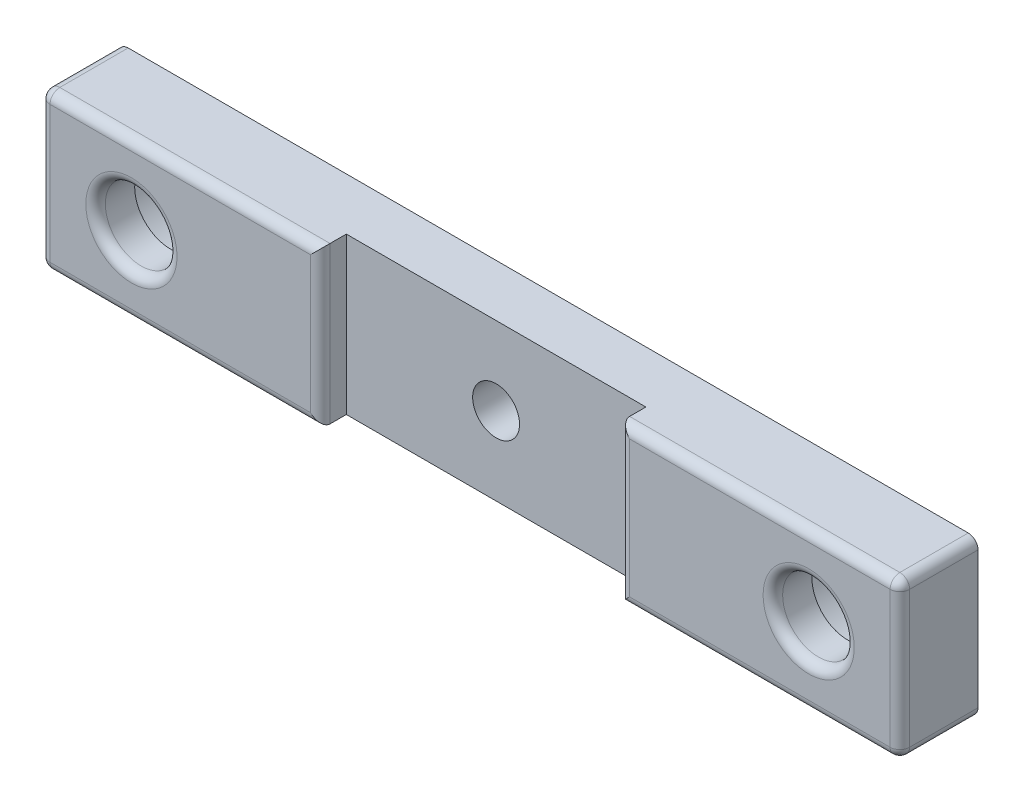
from build123d import *

# Parameters (mm, degrees)
ESQUISSE2_W             = 66
ESQUISSE2_H             = 12
BOSS_EXTRU_1_DEPTH      = 6
ESQUISSE3_W             = 23
ESQUISSE3_H             = 12
ENL_V_MAT_EXTRU_1_DEPTH = 2
ESQUISSE4_R             = 1.8
ENL_V_MAT_EXTRU_2_DEPTH = 5
ESQUISSE5_R             = 2.75
ENL_V_MAT_EXTRU_3_DEPTH = 7
ESQUISSE6_R             = 5.1
ENL_V_MAT_EXTRU_4_DEPTH = 3
CONG_1_R                = 0.75


with BuildPart() as part:
    # Esquisse2 → Boss.-Extru.1 (new body)
    with BuildSketch(Plane.XY):
        with Locations((33, 6)):
            Rectangle(ESQUISSE2_W, ESQUISSE2_H)
    extrude(amount=BOSS_EXTRU_1_DEPTH)

    # Esquisse3 → Enlèv. mat.-Extru.1 (cut)
    with BuildSketch(Plane.XY.offset(6)):
        with Locations((33, 6)):
            Rectangle(ESQUISSE3_W, ESQUISSE3_H)
    extrude(amount=-ENL_V_MAT_EXTRU_1_DEPTH, mode=Mode.SUBTRACT)

    # Esquisse4 → Enlèv. mat.-Extru.2 (cut, through all)
    with BuildSketch(Plane.XY.offset(4)):
        with Locations((33, 6)):
            Circle(ESQUISSE4_R)
    extrude(amount=-ENL_V_MAT_EXTRU_2_DEPTH, mode=Mode.SUBTRACT)

    # Esquisse5 → Enlèv. mat.-Extru.3 (cut, through all)
    with BuildSketch(Plane(origin=(0, 0, 0), x_dir=(-1, 0, 0), z_dir=(0, 0, -1))):
        with Locations((-59, 6)):
            Circle(ESQUISSE5_R)
        with Locations((-7, 6)):
            Circle(ESQUISSE5_R)
    extrude(amount=-ENL_V_MAT_EXTRU_3_DEPTH, mode=Mode.SUBTRACT)

    # Esquisse6 → Enlèv. mat.-Extru.4 (cut)
    with BuildSketch(Plane(origin=(0, 0, 0), x_dir=(-1, 0, 0), z_dir=(0, 0, -1))):
        with Locations((-59, 6)):
            Circle(ESQUISSE6_R)
        with Locations((-7, 6)):
            Circle(ESQUISSE6_R)
    extrude(amount=-ENL_V_MAT_EXTRU_4_DEPTH, mode=Mode.SUBTRACT)

    # Congé1
    cong_1_edges = [part.edges().sort_by_distance(p)[0] for p in [
        (66, 6, 6),
        (55.25, 12, 6),
        (55.25, 0, 6),
        (10.75, 12, 6),
        (21.5, 6, 6),
        (44.5, 6, 6),
        (61.75, 6, 6),
        (0, 6, 6),
        (9.75, 6, 6),
        (10.75, 0, 6),
        (0, 12, 3),
        (66, 12, 3),
        (66, 0, 3),
        (0, 0, 3),
    ]]
    fillet(cong_1_edges, radius=CONG_1_R)


solid = part.part
